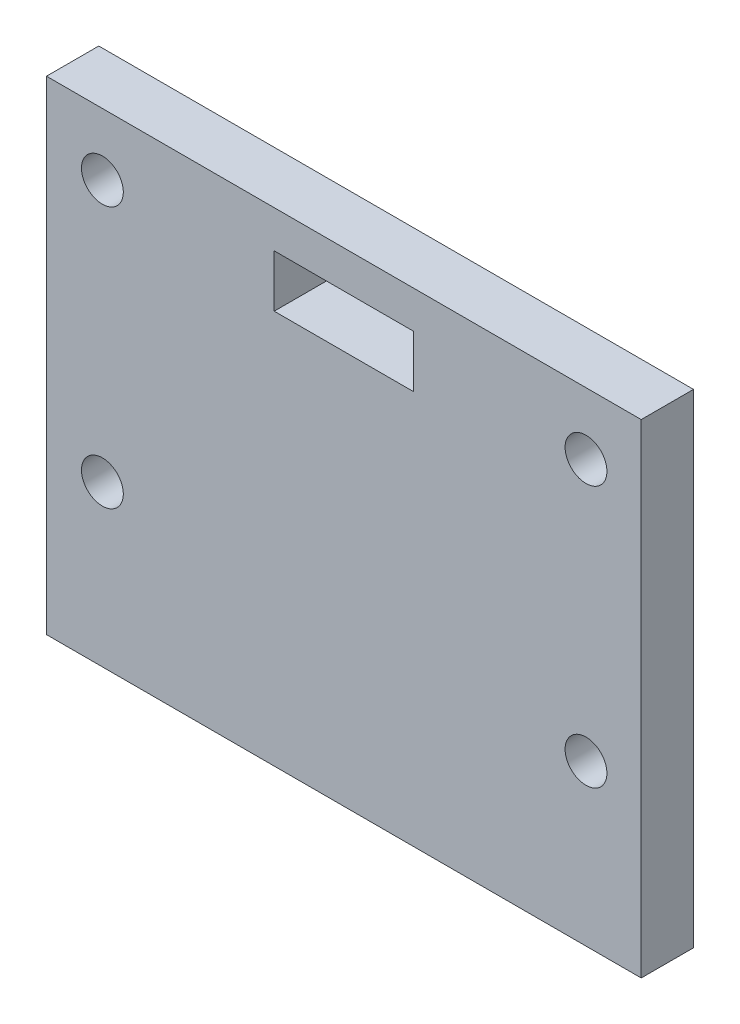
from build123d import *

# Parameters (mm, degrees)
SKETCH1_W               = 45.5
SKETCH1_H               = 37
SKETCH1_W_2             = 10.66
SKETCH1_H_2             = 4
BOSS_EXTRUDE1_DEPTH     = 4
SKETCH3_R               = 1.6
CUT_EXTRUDE5_DEPTH      = 10
CUT_EXTRUDE5_DEPTH_BACK = 1


with BuildPart() as part:
    # Sketch1 → Boss-Extrude1 (new body)
    with BuildSketch(Plane.XY):
        with Locations((22.75, 18.5)):
            Rectangle(SKETCH1_W, SKETCH1_H)
        with Locations((22.75, 32.14)):
            Rectangle(SKETCH1_W_2, SKETCH1_H_2, mode=Mode.SUBTRACT)
    extrude(amount=BOSS_EXTRUDE1_DEPTH)

    # Sketch3 → Cut-Extrude5 (cut, two sides)
    with BuildSketch(Plane.XY) as cut_extrude5_sk:
        with Locations((41.27584891, 32.252592082)):
            Circle(SKETCH3_R)
        with Locations((41.27584891, 12.252592082)):
            Circle(SKETCH3_R)
        with Locations((4.27584891, 12.252592082)):
            Circle(SKETCH3_R)
        with Locations((4.27584891, 32.252592082)):
            Circle(SKETCH3_R)
    extrude(amount=CUT_EXTRUDE5_DEPTH, mode=Mode.SUBTRACT)
    extrude(cut_extrude5_sk.sketch, amount=-CUT_EXTRUDE5_DEPTH_BACK, mode=Mode.SUBTRACT)


solid = part.part
